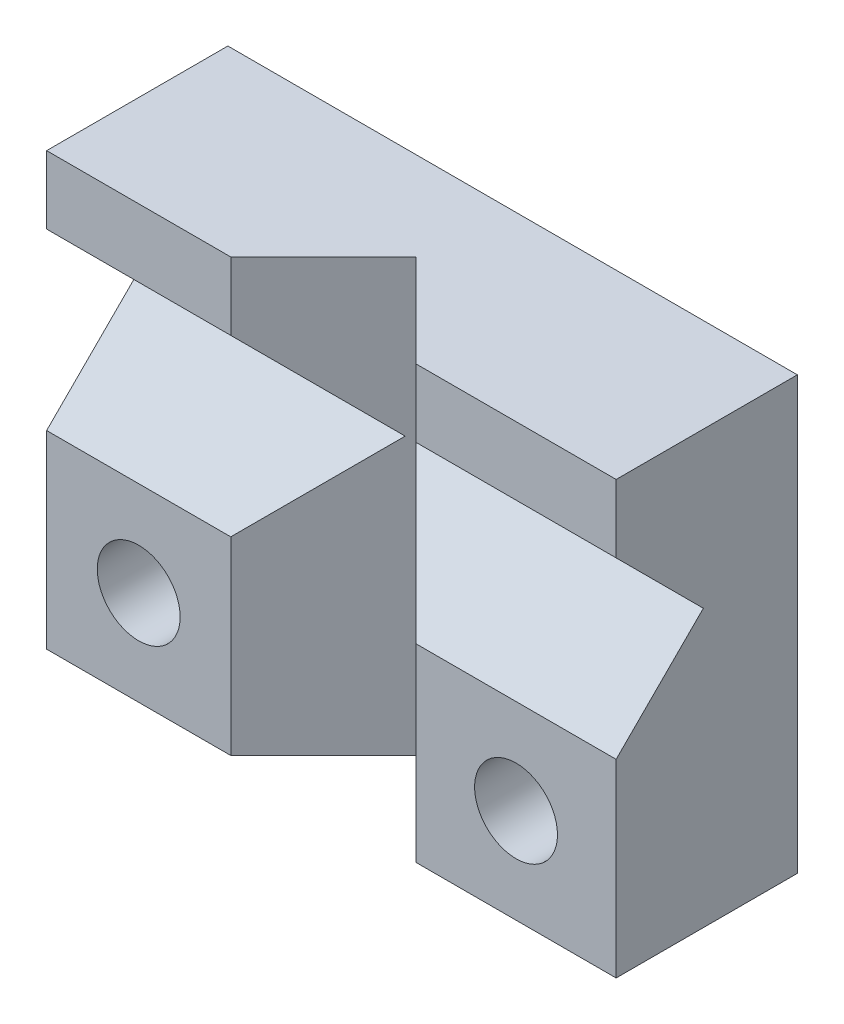
from build123d import *

# Parameters (mm, degrees)
SKETCH1_W                 = 12.57
SKETCH1_H                 = 9.53
BOSS_EXTRUDE1_DEPTH       = 4
CUT_EXTRUDE1_REACH        = 14.57
CUT_EXTRUDE2_REACH        = 11.53
F_1_72_TAPPED_HOLE1_D     = 1.8288
F_1_72_TAPPED_HOLE1_DEPTH = 4


with BuildPart() as part:
    # Sketch1 → Boss-Extrude1 (new body)
    with BuildSketch(Plane.XY):
        Rectangle(SKETCH1_W, SKETCH1_H)
    extrude(amount=BOSS_EXTRUDE1_DEPTH)

    # Sketch2 → Cut-Extrude1 (cut, up to next)
    with BuildSketch(Plane.ZY.offset(6.285), mode=Mode.PRIVATE) as cut_extrude1_sk1:
        Polygon((4, 3.265), (4, -0.585), (2.075, 1.34), align=None)
    cut_extrude1_tool1 = extrude(cut_extrude1_sk1.sketch, amount=-CUT_EXTRUDE1_REACH, mode=Mode.PRIVATE) & part.part
    add(cut_extrude1_tool1.solids().sort_by_distance((-6.285, 1.34, 3.358333))[0], mode=Mode.SUBTRACT)

    # Sketch3 → Cut-Extrude2 (cut, up to next)
    with BuildSketch(Plane(origin=(0, 4.765, 0), x_dir=(1, 0, 0), z_dir=(0, 1, 0)), mode=Mode.PRIVATE) as cut_extrude2_sk1:
        Polygon((-2.221, -4), (-0.177343653, -1.956343653), (1.866312693, -4), align=None)
    cut_extrude2_tool1 = extrude(cut_extrude2_sk1.sketch, amount=-CUT_EXTRUDE2_REACH, mode=Mode.PRIVATE) & part.part
    add(cut_extrude2_tool1.solids().sort_by_distance((-0.177344, 4.765, 3.318781))[0], mode=Mode.SUBTRACT)

    # #1-72 Tapped Hole1
    with Locations(Plane.XY.offset(4)):
        with Locations((-4.253, -2.675), (4.075656347, -2.675)):
            Hole(F_1_72_TAPPED_HOLE1_D / 2, depth=F_1_72_TAPPED_HOLE1_DEPTH)


solid = part.part
